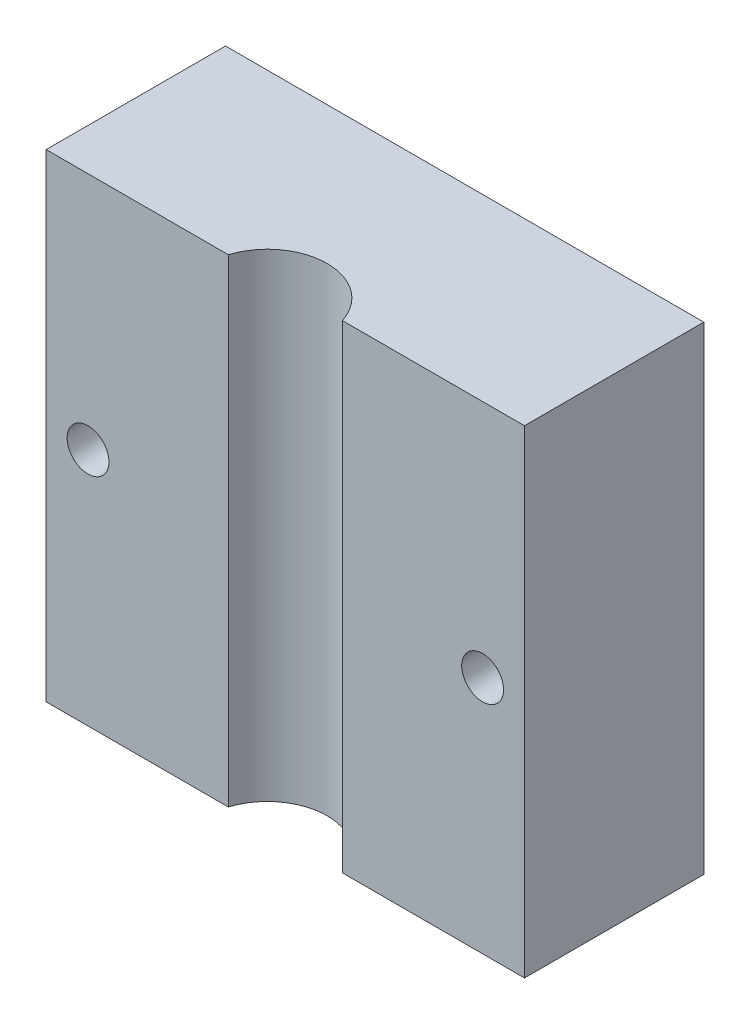
from build123d import *

# Parameters (mm, degrees)
SKETCH1_W           = 40
SKETCH1_H           = 40
BOSS_EXTRUDE1_DEPTH = 15
SKETCH2_R           = 1.75
CUT_EXTRUDE1_DEPTH  = 16
SKETCH3_R           = 5
CUT_EXTRUDE2_DEPTH  = 41


with BuildPart() as part:
    # Sketch1 → Boss-Extrude1 (new body)
    with BuildSketch(Plane.XY):
        Rectangle(SKETCH1_W, SKETCH1_H)
    extrude(amount=BOSS_EXTRUDE1_DEPTH)

    # Sketch2 → Cut-Extrude1 (cut, through all)
    with BuildSketch(Plane.XY.offset(15)):
        with Locations((-16.5, 0)):
            Circle(SKETCH2_R)
        with Locations((16.5, 0)):
            Circle(SKETCH2_R)
    extrude(amount=-CUT_EXTRUDE1_DEPTH, mode=Mode.SUBTRACT)

    # Sketch3 → Cut-Extrude2 (cut, through all)
    with BuildSketch(Plane(origin=(0, 20, 0), x_dir=(1, 0, 0), z_dir=(0, 1, 0))):
        with Locations((0, -16.5)):
            Circle(SKETCH3_R)
    extrude(amount=-CUT_EXTRUDE2_DEPTH, mode=Mode.SUBTRACT)


solid = part.part
